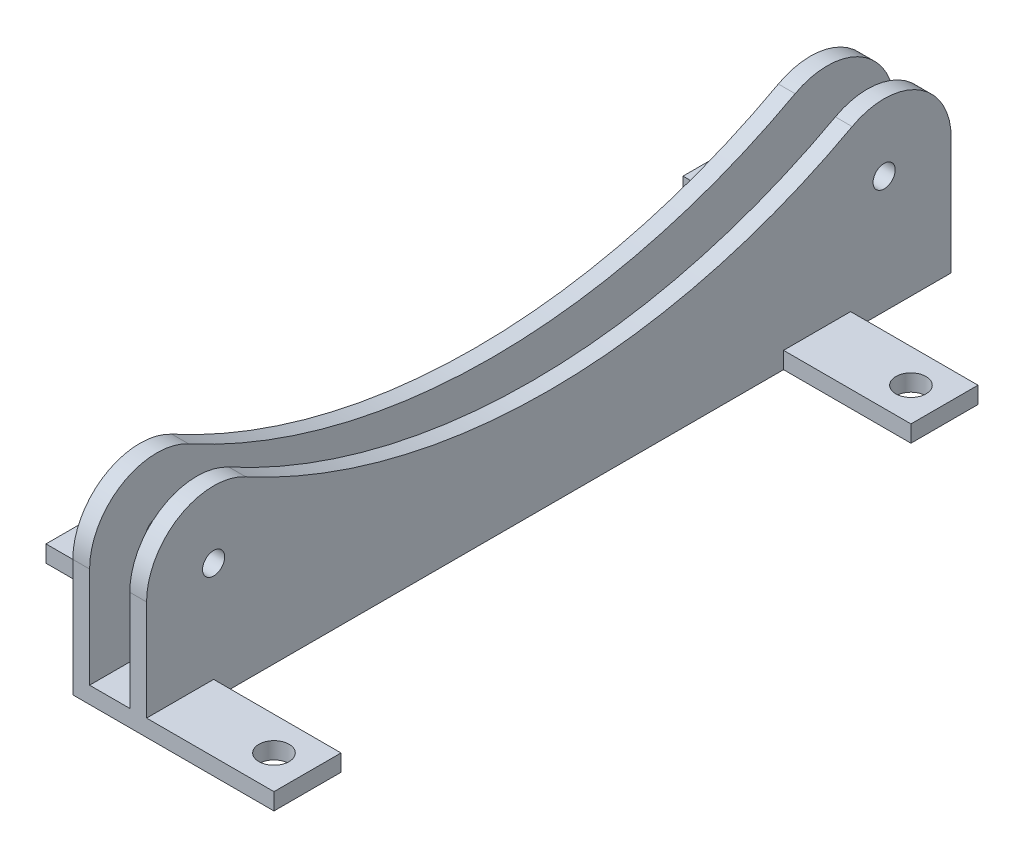
from build123d import *

# Parameters (mm, degrees)
BOSS_EXTRUDE1_DEPTH        = 2.5
BOSS_EXTRUDE2_START        = -6
BOSS_EXTRUDE2_DEPTH        = 2.5
BOSS_EXTRUDE3_REACH        = 68.547
SKETCH4_W                  = 120
SKETCH4_H                  = 2.5
M4X0_7_TAPPED_HOLE1_D      = 3.3
SKETCH5_W                  = 30
SKETCH5_H                  = 10
BOSS_EXTRUDE4_DEPTH        = 2.5
F_4_5_4_5_DIAMETER_HOLE1_D = 4.5


with BuildPart() as part:
    # Sketch1 → Boss-Extrude1 (new body)
    with BuildSketch(Plane(origin=(0, 0, 0), x_dir=(0, 0, -1), z_dir=(1, 0, 0))):
        with BuildLine():
            Line((-60, 17.5), (-60, 0))
            Line((-60, 0), (60, 0))
            Line((60, 0), (60, 17.5))
            ThreePointArc((60, 17.5), (55.112108327, 26.094553418), (45.22673031, 26.287257619))
            ThreePointArc((45.22673031, 26.287257619), (0, 14.796523563), (-45.22673031, 26.287257619))
            ThreePointArc((-45.22673031, 26.287257619), (-55.112108327, 26.094553418), (-60, 17.5))
        make_face()
    extrude(amount=BOSS_EXTRUDE1_DEPTH)


with BuildPart() as body_2:
    # Sketch1_2 → Boss-Extrude2 (new body)
    with BuildSketch(Plane(origin=(0, 0, 0), x_dir=(0, 0, -1), z_dir=(1, 0, 0)).offset(BOSS_EXTRUDE2_START)):
        with BuildLine():
            Line((-60, 17.5), (-60, 0))
            Line((-60, 0), (60, 0))
            Line((60, 0), (60, 17.5))
            ThreePointArc((60, 17.5), (55.112108327, 26.094553418), (45.22673031, 26.287257619))
            ThreePointArc((45.22673031, 26.287257619), (0, 14.796523563), (-45.22673031, 26.287257619))
            ThreePointArc((-45.22673031, 26.287257619), (-55.112108327, 26.094553418), (-60, 17.5))
        make_face()
    extrude(amount=-BOSS_EXTRUDE2_DEPTH)

    # Sketch4 → Boss-Extrude3 (add, up to next)
    with BuildSketch(Plane.ZY, mode=Mode.PRIVATE) as boss_extrude3_sk1:
        with Locations((0, 1.25)):
            Rectangle(SKETCH4_W, SKETCH4_H)
    boss_extrude3_tool1 = extrude(boss_extrude3_sk1.sketch, amount=BOSS_EXTRUDE3_REACH, mode=Mode.PRIVATE) - body_2.part

    add(part.part)  # Boss-Extrude3 merges part
    add(boss_extrude3_tool1.solids().sort_by_distance((0, 1.25, 0))[0])

    # M4x0.7 Tapped Hole1 (through all)
    with Locations(Plane(origin=(2.5, 0, 0), x_dir=(0, 0, 1), z_dir=(1, 0, 0))):
        with Locations((-50, -17.5), (50, -17.5)):
            Hole(M4X0_7_TAPPED_HOLE1_D / 2)

    # Sketch5 → Boss-Extrude4 (add)
    with BuildSketch(Plane.XZ):
        with Locations((-12.5, 40)):
            Rectangle(SKETCH5_W, SKETCH5_H)
        with Locations((-12.5, -55)):
            Rectangle(SKETCH5_W, SKETCH5_H)
        with Locations((6.5, 55)):
            Rectangle(SKETCH5_W, SKETCH5_H)
        with Locations((6.5, -40)):
            Rectangle(SKETCH5_W, SKETCH5_H)
    extrude(amount=-BOSS_EXTRUDE4_DEPTH)

    # Ø4.5 (4.5) Diameter Hole1 (through all)
    with Locations(Plane(origin=(0, 2.5, 0), x_dir=(1, 0, 0), z_dir=(0, 1, 0))):
        with Locations((-22.5, 55), (16.5, 40), (16.5, -55), (-22.5, -40)):
            Hole(F_4_5_4_5_DIAMETER_HOLE1_D / 2)


solid = body_2.part
